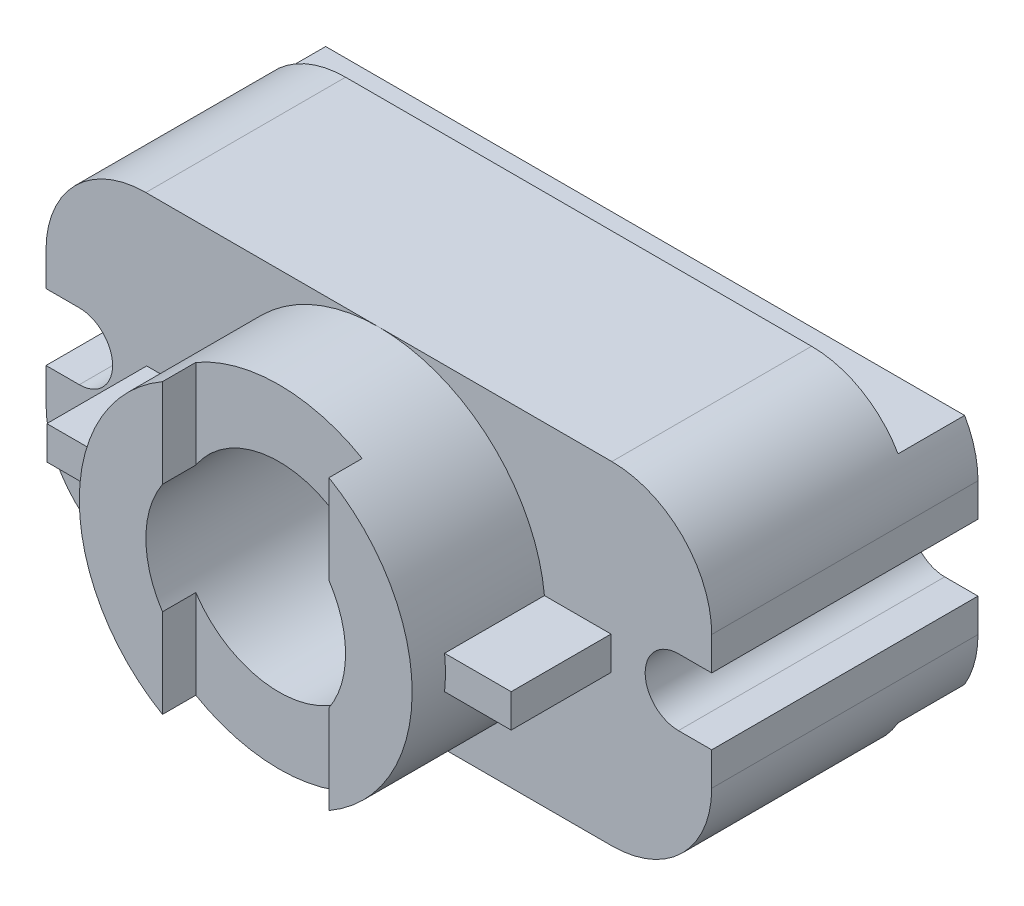
from build123d import *

# Parameters (mm, degrees)
SKETCH1_W           = 200
SKETCH1_H           = 100
BOSS_EXTRUDE1_DEPTH = 100
CUT_EXTRUDE2_DEPTH  = 100
CUT_EXTRUDE3_DEPTH  = 100
SKETCH4_W           = 20
SKETCH4_H           = 15
CUT_EXTRUDE8_DEPTH  = 275
SKETCH8_R           = 10
CUT_EXTRUDE9_DEPTH  = 275
SKETCH9_R           = 30
SKETCH9_R_2         = 10
CUT_EXTRUDE10_DEPTH = 50
SKETCH10_R          = 50
SKETCH10_R_2        = 30
BOSS_EXTRUDE2_DEPTH = 20
CUT_EXTRUDE12_DEPTH = 10
SKETCH12_W          = 20
SKETCH12_H          = 10
BOSS_EXTRUDE3_DEPTH = 10
SKETCH13_W          = 20
SKETCH13_H          = 10
BOSS_EXTRUDE4_DEPTH = 10
CUT_EXTRUDE13_DEPTH = 20
SKETCH15_R          = 50
SKETCH15_R_2        = 30
BOSS_EXTRUDE5_DEPTH = 20
SKETCH16_W          = 20
SKETCH16_H          = 10
BOSS_EXTRUDE6_DEPTH = 30


with BuildPart() as part:
    # Sketch1 → Boss-Extrude1 (new body)
    with BuildSketch(Plane.XY):
        with Locations((100, 50)):
            Rectangle(SKETCH1_W, SKETCH1_H)
    extrude(amount=BOSS_EXTRUDE1_DEPTH)

    # Sketch2 → Cut-Extrude2 (cut)
    with BuildSketch(Plane.XY.offset(100)):
        with BuildLine():
            Line((30, 100), (0, 100))
            Line((0, 100), (0, 70))
            ThreePointArc((0, 70), (8.786796564, 91.213203436), (30, 100))
        make_face()
        with BuildLine():
            Line((200, 100), (170, 100))
            ThreePointArc((170, 100), (191.213203436, 91.213203436), (200, 70))
            Line((200, 70), (200, 100))
        make_face()
        with BuildLine():
            Line((200, 0), (200, 30))
            ThreePointArc((200, 30), (191.213203436, 8.786796564), (170, 0))
            Line((170, 0), (200, 0))
        make_face()
        with BuildLine():
            ThreePointArc((30, 0), (8.786796564, 8.786796564), (0, 30))
            Line((0, 30), (0, 0))
            Line((0, 0), (30, 0))
        make_face()
    extrude(amount=-CUT_EXTRUDE2_DEPTH, mode=Mode.SUBTRACT)

    # Sketch3 → Cut-Extrude3 (cut)
    with BuildSketch(Plane.XY.offset(100)):
        with BuildLine():
            Line((10, 60), (0, 60))
            Line((0, 60), (0, 40))
            Line((0, 40), (10, 40))
            ThreePointArc((10, 40), (20, 50), (10, 60))
        make_face()
        with BuildLine():
            Line((190, 60), (200, 60))
            Line((200, 60), (200, 40))
            Line((200, 40), (190, 40))
            ThreePointArc((190, 40), (180, 50), (190, 60))
        make_face()
    extrude(amount=-CUT_EXTRUDE3_DEPTH, mode=Mode.SUBTRACT)

    # Sketch4 → Cut-Extrude8 (cut)
    with BuildSketch(Plane(origin=(0, 0, 0), x_dir=(0, 0, -1), z_dir=(1, 0, 0))):
        with Locations((-10, 92.5)):
            Rectangle(SKETCH4_W, SKETCH4_H)
        with Locations((-10, 7.5)):
            Rectangle(SKETCH4_W, SKETCH4_H)
    extrude(amount=CUT_EXTRUDE8_DEPTH, mode=Mode.SUBTRACT)

    # Sketch8 → Cut-Extrude9 (cut)
    with BuildSketch(Plane.XY.offset(100)):
        with Locations((100, 50)):
            Circle(SKETCH8_R)
    extrude(amount=-CUT_EXTRUDE9_DEPTH, mode=Mode.SUBTRACT)

    # Sketch9 → Cut-Extrude10 (cut)
    with BuildSketch(Plane.XY.offset(100)):
        with Locations((100, 50)):
            Circle(SKETCH9_R)
        with Locations((100, 50)):
            Circle(SKETCH9_R_2, mode=Mode.SUBTRACT)
    extrude(amount=-CUT_EXTRUDE10_DEPTH, mode=Mode.SUBTRACT)

    # Sketch10 → Boss-Extrude2 (add)
    with BuildSketch(Plane.XY.offset(100)):
        with Locations((100, 50)):
            Circle(SKETCH10_R)
        with Locations((100, 50)):
            Circle(SKETCH10_R_2, mode=Mode.SUBTRACT)
    extrude(amount=BOSS_EXTRUDE2_DEPTH)

    # Sketch11 → Cut-Extrude12 (cut)
    with BuildSketch(Plane.XY.offset(120)):
        with BuildLine():
            ThreePointArc((125, 93.301270189), (100, 100), (75, 93.301270189))
            Line((75, 93.301270189), (75, 66.583123952))
            ThreePointArc((75, 66.583123952), (100, 80), (125, 66.583123952))
            Line((125, 66.583123952), (125, 93.301270189))
        make_face()
        with BuildLine():
            Line((75, 33.416876048), (75, 6.698729811))
            ThreePointArc((75, 6.698729811), (100, 0), (125, 6.698729811))
            Line((125, 6.698729811), (125, 33.416876048))
            ThreePointArc((125, 33.416876048), (100, 20), (75, 33.416876048))
        make_face()
    extrude(amount=-CUT_EXTRUDE12_DEPTH, mode=Mode.SUBTRACT)

    # Sketch12 → Boss-Extrude3 (add)
    with BuildSketch(Plane.XY.offset(100)):
        with Locations((40.250628145, 50)):
            Rectangle(SKETCH12_W, SKETCH12_H)
    extrude(amount=BOSS_EXTRUDE3_DEPTH)

    # Sketch13 → Boss-Extrude4 (add)
    with BuildSketch(Plane.XY.offset(100)):
        with Locations((159.749371855, 50)):
            Rectangle(SKETCH13_W, SKETCH13_H)
    extrude(amount=BOSS_EXTRUDE4_DEPTH)

    # Sketch14 → Cut-Extrude13 (cut)
    with BuildSketch(Plane.XY.offset(100)):
        with BuildLine():
            ThreePointArc((200, 30), (191.213203436, 8.786796564), (170, 0))
            Line((170, 0), (170, 100))
            ThreePointArc((170, 100), (191.213203436, 91.213203436), (200, 70))
            Line((200, 70), (200, 60))
            Line((200, 60), (190, 60))
            ThreePointArc((190, 60), (180, 50), (190, 40))
            Line((190, 40), (200, 40))
            Line((200, 40), (200, 30))
        make_face()
        with BuildLine():
            Line((170, 100), (100, 100))
            ThreePointArc((100, 100), (66.458980338, 87.080992435), (50.250628145, 55))
            Line((50.250628145, 55), (30.250628145, 55))
            Line((30.250628145, 55), (30.250628145, 45))
            Line((30.250628145, 45), (50.250628145, 45))
            ThreePointArc((50.250628145, 45), (66.458980338, 12.919007565), (100, 0))
            Line((100, 0), (170, 0))
            Line((170, 0), (170, 100))
        make_face()
        with BuildLine():
            Line((30, 100), (30, 0))
            Line((30, 0), (100, 0))
            ThreePointArc((100, 0), (66.458980338, 12.919007565), (50.250628145, 45))
            Line((50.250628145, 45), (30.250628145, 45))
            Line((30.250628145, 45), (30.250628145, 55))
            Line((30.250628145, 55), (50.250628145, 55))
            ThreePointArc((50.250628145, 55), (66.458980338, 87.080992435), (100, 100))
            Line((100, 100), (30, 100))
        make_face()
        with BuildLine():
            Line((30, 100), (30, 0))
            ThreePointArc((30, 0), (8.786796564, 8.786796564), (0, 30))
            Line((0, 30), (0, 40))
            Line((0, 40), (10, 40))
            ThreePointArc((10, 40), (20, 50), (10, 60))
            Line((10, 60), (0, 60))
            Line((0, 60), (0, 70))
            ThreePointArc((0, 70), (8.786796564, 91.213203436), (30, 100))
        make_face()
    extrude(amount=-CUT_EXTRUDE13_DEPTH, mode=Mode.SUBTRACT)

    # Sketch15 → Boss-Extrude5 (add)
    with BuildSketch(Plane(origin=(0, 0, 100), x_dir=(-1, 0, 0), z_dir=(0, 0, -1))):
        with Locations((-100, 50)):
            Circle(SKETCH15_R)
        with Locations((-100, 50)):
            Circle(SKETCH15_R_2, mode=Mode.SUBTRACT)
    extrude(amount=BOSS_EXTRUDE5_DEPTH)

    # Sketch16 → Boss-Extrude6 (add)
    with BuildSketch(Plane.XY.offset(110)):
        with Locations((40.250628145, 50)):
            Rectangle(SKETCH16_W, SKETCH16_H)
        with Locations((159.749371855, 50)):
            Rectangle(SKETCH16_W, SKETCH16_H)
    extrude(amount=-BOSS_EXTRUDE6_DEPTH)


solid = part.part
